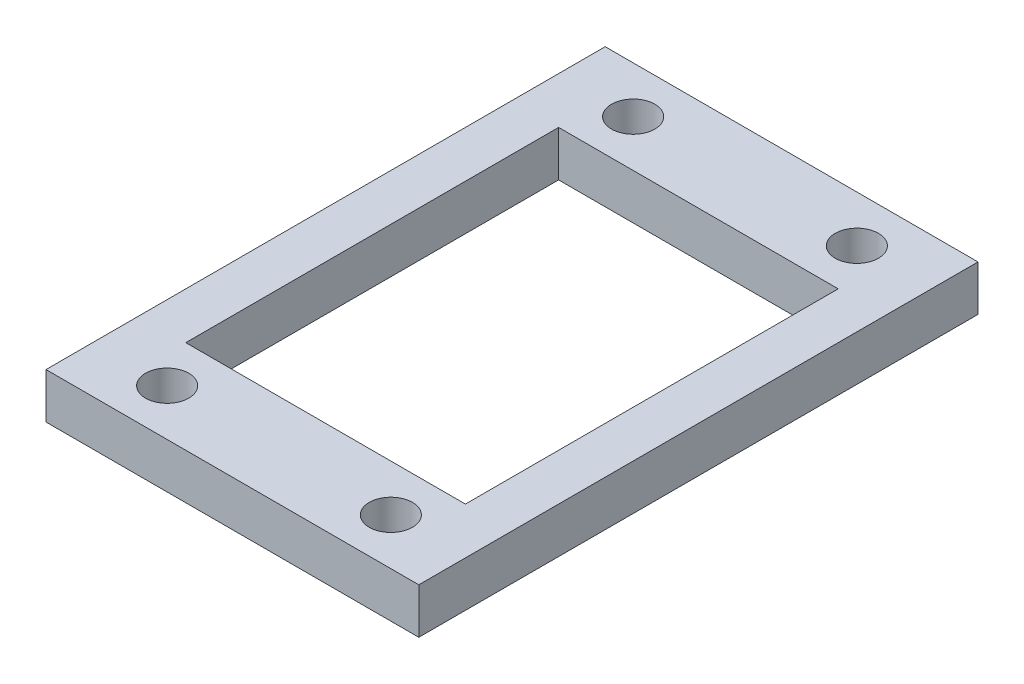
from build123d import *

# Parameters (mm, degrees)
SKETCH1_W           = 25.4
SKETCH1_H           = 38.1
SKETCH1_R           = 1.4732
SKETCH1_W_2         = 19.05
SKETCH1_H_2         = 25.4
BOSS_EXTRUDE1_DEPTH = 3.0988


with BuildPart() as part:
    # Sketch1 → Boss-Extrude1 (new body)
    with BuildSketch(Plane(origin=(0, 0, 0), x_dir=(1, 0, 0), z_dir=(0, 1, 0))):
        with Locations((-12.7, 0)):
            Rectangle(SKETCH1_W, SKETCH1_H)
        with Locations((-5.08, 15.875)):
            Circle(SKETCH1_R, mode=Mode.SUBTRACT)
        with Locations((-20.32, -15.875)):
            Circle(SKETCH1_R, mode=Mode.SUBTRACT)
        with Locations((-20.32, 15.875)):
            Circle(SKETCH1_R, mode=Mode.SUBTRACT)
        with Locations((-5.08, -15.875)):
            Circle(SKETCH1_R, mode=Mode.SUBTRACT)
        with Locations((-12.7, 0)):
            Rectangle(SKETCH1_W_2, SKETCH1_H_2, mode=Mode.SUBTRACT)
    extrude(amount=BOSS_EXTRUDE1_DEPTH)


solid = part.part
